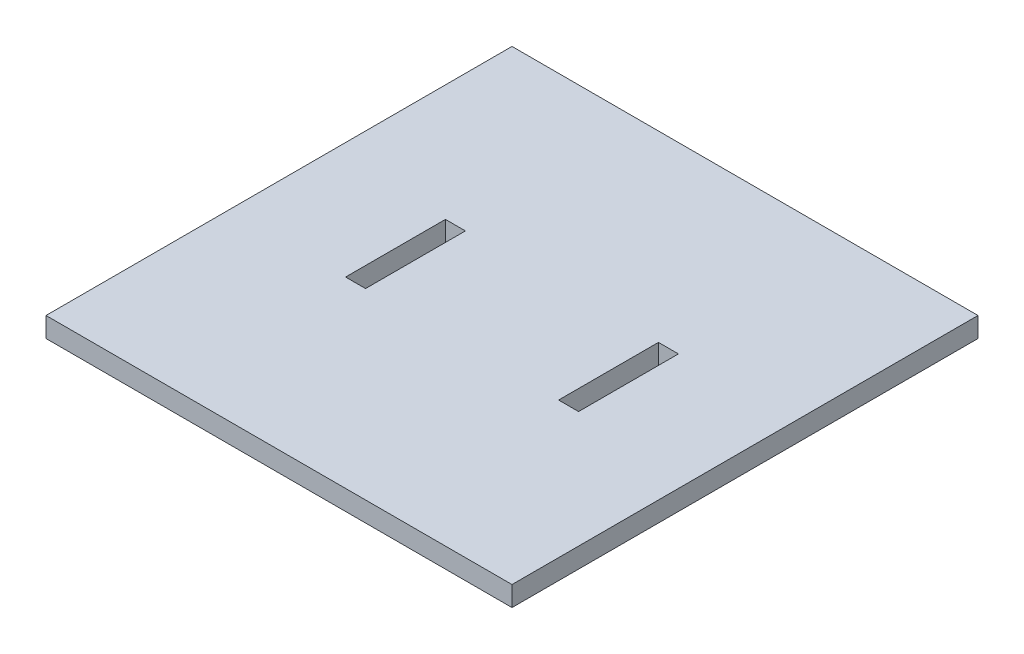
from build123d import *

# Parameters (mm, degrees)
ESBO_O1_W                = 70
ESBO_O1_H                = 70
RESSALTO_EXTRUS_O1_DEPTH = 3
ESBO_O2_W                = 3
ESBO_O2_H                = 15
CORTE_EXTRUS_O1_DEPTH    = 3


with BuildPart() as part:
    # Esboço1 → Ressalto-extrusão1 (new body)
    with BuildSketch(Plane(origin=(0, 0, 0), x_dir=(1, 0, 0), z_dir=(0, 1, 0))):
        with Locations((20.850515464, -7.641752577)):
            Rectangle(ESBO_O1_W, ESBO_O1_H)
    extrude(amount=RESSALTO_EXTRUS_O1_DEPTH)

    # Esboço2 → Corte-extrusão1 (cut)
    with BuildSketch(Plane(origin=(0, 3, 0), x_dir=(1, 0, 0), z_dir=(0, 1, 0))):
        with Locations((4.850515464, -7.641752577)):
            Rectangle(ESBO_O2_W, ESBO_O2_H)
        with Locations((36.850515464, -7.641752577)):
            Rectangle(ESBO_O2_W, ESBO_O2_H)
    extrude(amount=-CORTE_EXTRUS_O1_DEPTH, mode=Mode.SUBTRACT)


solid = part.part
